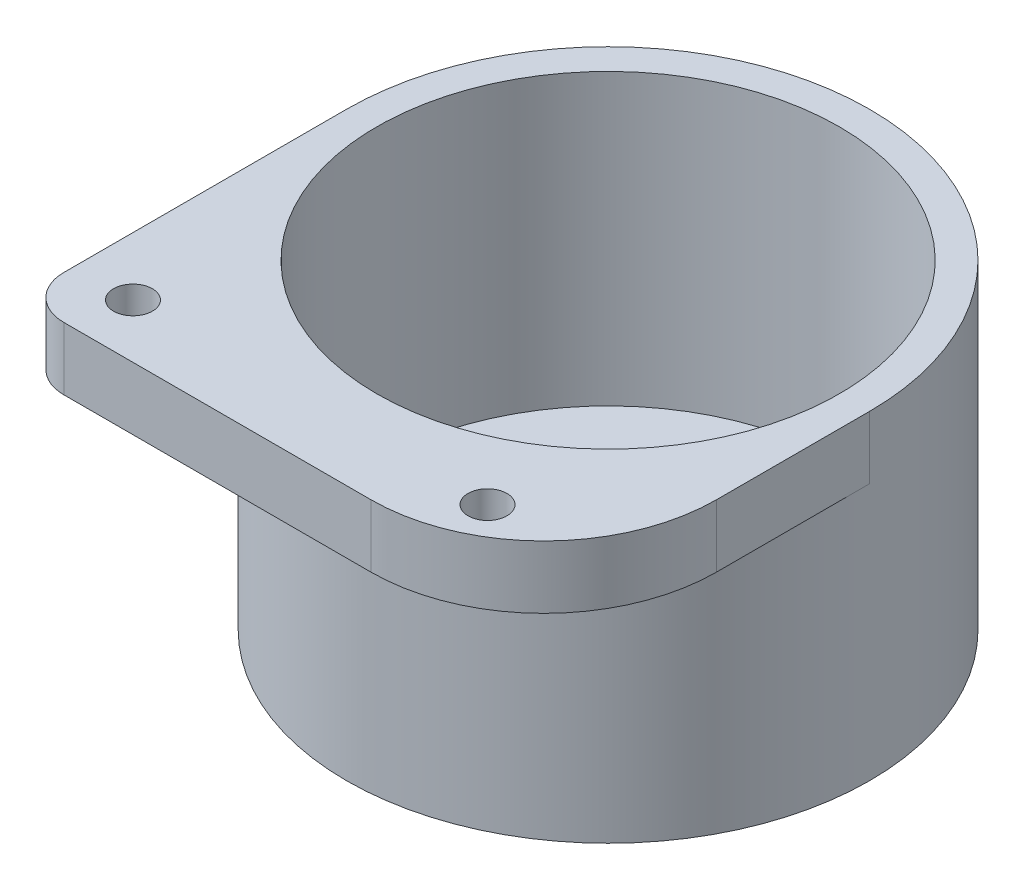
from build123d import *

# Parameters (mm, degrees)
SKETCH_1_R          = 60.5
EXTRUDE_1_DEPTH     = 7
SKETCH_2_R          = 60.5
SKETCH_2_R_2        = 53.5
EXTRUDE_2_DEPTH     = 67
SKETCH_3_R          = 17.75
CUT_EXTRUDE_1_DEPTH = 54
SKETCH_6_R          = 4.5
EXTRUDE_3_DEPTH     = 14.5


with BuildPart() as part:
    # Эскиз1 → Бобышка-Вытянуть1 (new body)
    with BuildSketch(Plane(origin=(0, 0, 0), x_dir=(1, 0, 0), z_dir=(0, 1, 0))):
        Circle(SKETCH_1_R)
    extrude(amount=EXTRUDE_1_DEPTH)

    # Эскиз2 → Бобышка-Вытянуть2 (add)
    with BuildSketch(Plane(origin=(0, 7, 0), x_dir=(1, 0, 0), z_dir=(0, 1, 0))):
        Circle(SKETCH_2_R)
        Circle(SKETCH_2_R_2, mode=Mode.SUBTRACT)
    extrude(amount=EXTRUDE_2_DEPTH)

    # Эскиз3 → Вырез-Вытянуть1 (cut)
    with BuildSketch(Plane(origin=(0, 7, 0), x_dir=(1, 0, 0), z_dir=(0, 1, 0))):
        Circle(SKETCH_3_R)
    extrude(amount=-CUT_EXTRUDE_1_DEPTH, mode=Mode.SUBTRACT)

    # Эскиз6 → Бобышка-Вытянуть3 (add)
    with BuildSketch(Plane(origin=(0, 74, 0), x_dir=(1, 0, 0), z_dir=(0, 1, 0))):
        with BuildLine():
            ThreePointArc((60.5, 0), (0, -60.5), (-60.5, 0))
            Line((-60.5, 0), (-60.5, -65.387945457))
            ThreePointArc((-60.5, -65.387945457), (-57.571067812, -72.459013269), (-50.5, -75.387945457))
            Line((-50.5, -75.387945457), (20.5, -75.387945457))
            ThreePointArc((20.5, -75.387945457), (48.784271247, -63.672216704), (60.5, -35.387945457))
            Line((60.5, -35.387945457), (60.5, 0))
        make_face()
        with Locations((-47, -62.890262607)):
            Circle(SKETCH_6_R, mode=Mode.SUBTRACT)
        with BuildLine():
            ThreePointArc((39.5, -62.890262607), (35, -67.390262607), (30.5, -62.890262607))
            ThreePointArc((30.5, -62.890262607), (35, -58.390262607), (39.5, -62.890262607))
        make_face(mode=Mode.SUBTRACT)
    extrude(amount=-EXTRUDE_3_DEPTH)


solid = part.part
